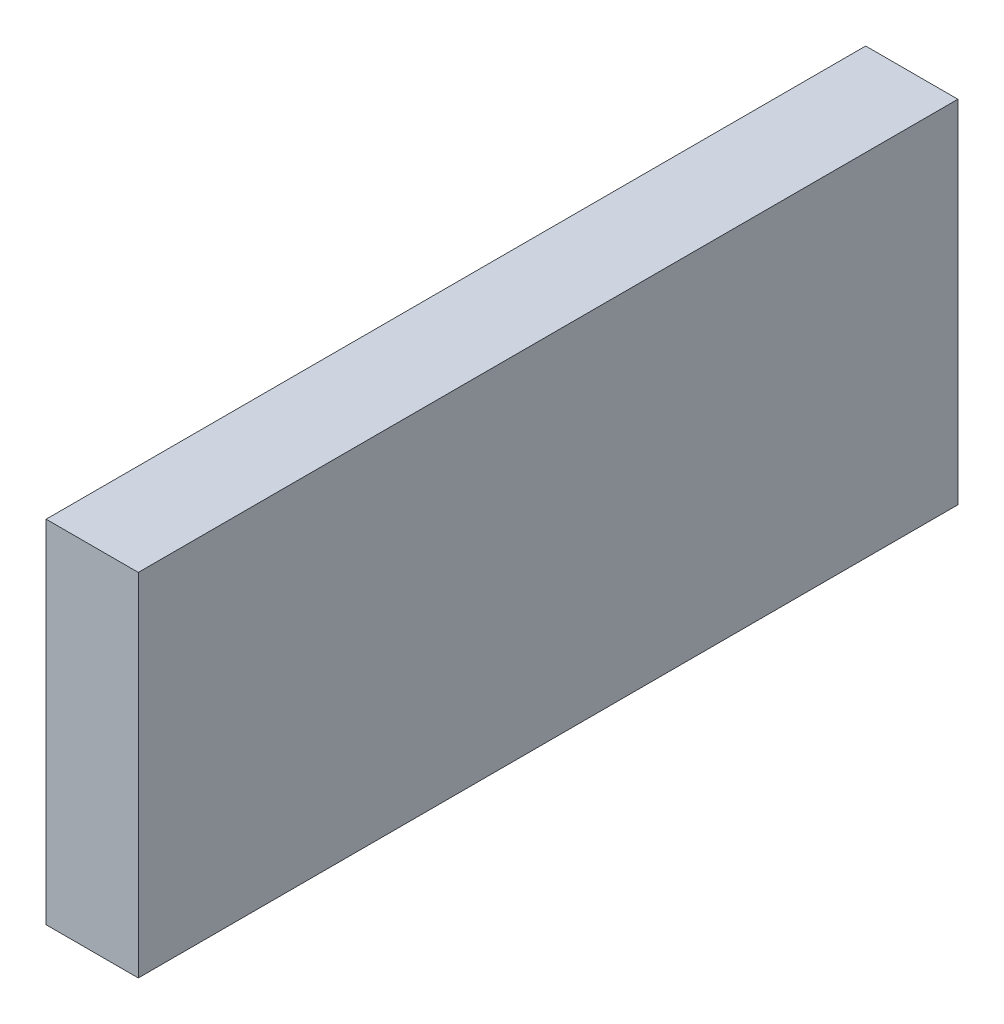
from build123d import *

# Parameters (mm, degrees)
SKETCH1_W           = 88.9
SKETCH1_H           = 38.1
BOSS_EXTRUDE1_DEPTH = 10


with BuildPart() as part:
    # Sketch1 → Boss-Extrude1 (new body)
    with BuildSketch(Plane(origin=(0, 0, 0), x_dir=(0, 0, -1), z_dir=(1, 0, 0))):
        Rectangle(SKETCH1_W, SKETCH1_H)
    extrude(amount=BOSS_EXTRUDE1_DEPTH)


solid = part.part
